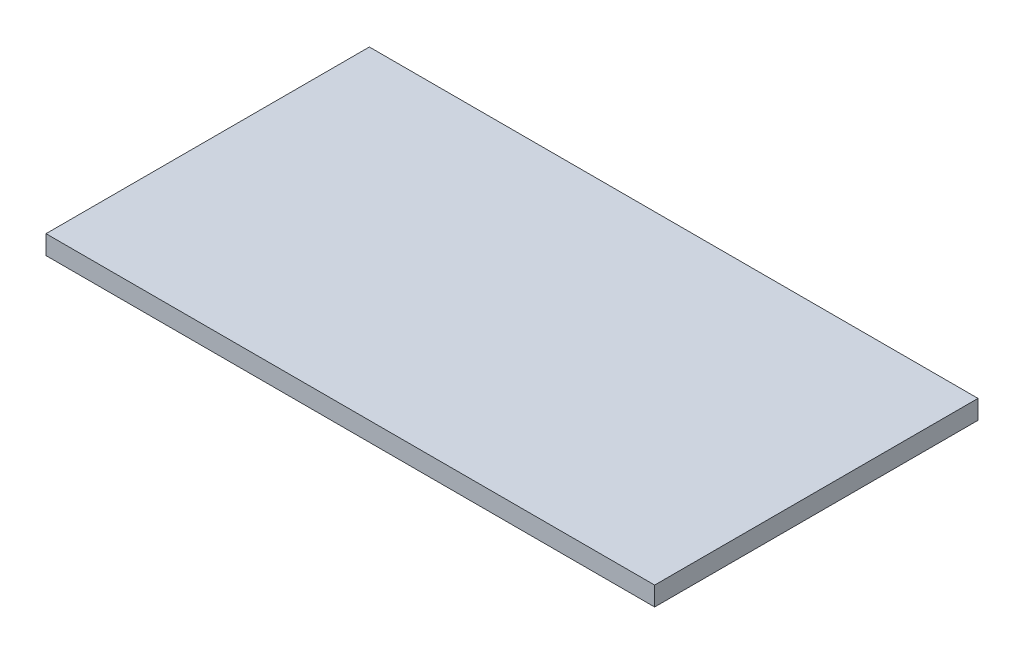
from build123d import *

# Parameters (mm, degrees)
SKETCH1_W           = 101.6
SKETCH1_H           = 53.975
BOSS_EXTRUDE1_DEPTH = 3.175


with BuildPart() as part:
    # Sketch1 → Boss-Extrude1 (new body)
    with BuildSketch(Plane(origin=(0, 0, 0), x_dir=(1, 0, 0), z_dir=(0, 1, 0))):
        Rectangle(SKETCH1_W, SKETCH1_H)
    extrude(amount=BOSS_EXTRUDE1_DEPTH)


solid = part.part
